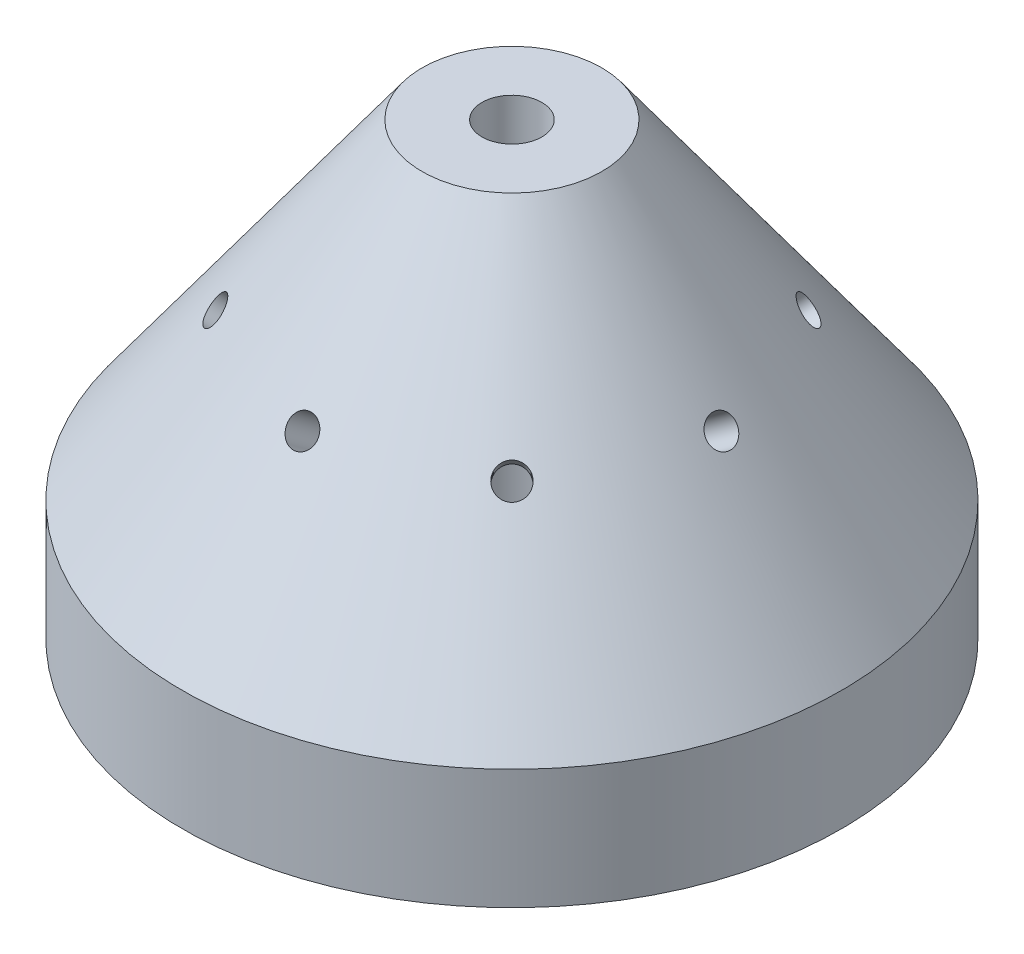
from build123d import *
from build123d.topology import SkipClean

# Parameters (mm, degrees)
KREISMUSTER1_COUNT = 8


with BuildPart() as part:
    # Skizze2 → Rotation1 (revolve)
    with BuildSketch(Plane.XY, mode=Mode.PRIVATE) as rotation1_sk:
        Polygon((-55, 20), (-55, 0), (-7.5, 0), (-7.5, 24.408756703), (-5, 28.773061479), (-5, 75), (-15, 75), align=None)
    revolve(rotation1_sk.sketch.rotate(Axis((0, 0, 0), (0, 1, 0)), 270), axis=Axis((0, 0, 0), (0, 1, 0)))  # turned: the seam where the file's is

    # Skizze3 → Schnitt-Rotation1 (revolve, cut)
    with SkipClean():  # keep this step's faces unmerged: merging them makes the solid invalid here
        with BuildSketch(Plane.XY):
            Polygon((-35, 47.5), (0, 22.045454545), (-1.470429244, 20.023614335), (-36.470429244, 45.478159789), align=None)
        schnitt_rotation1 = revolve(axis=Axis((-35, 47.5, 0), (0.808736084, -0.588171698, 0)), mode=Mode.SUBTRACT)

    # Kreismuster1: Schnitt-Rotation1 ×8 about axis
    kreismuster1_axis = Axis((0, 55, 0), (0, -1, 0))
    for i in range(1, KREISMUSTER1_COUNT):
        add(schnitt_rotation1.rotate(kreismuster1_axis, i * 360 / KREISMUSTER1_COUNT), mode=Mode.SUBTRACT)


solid = part.part
